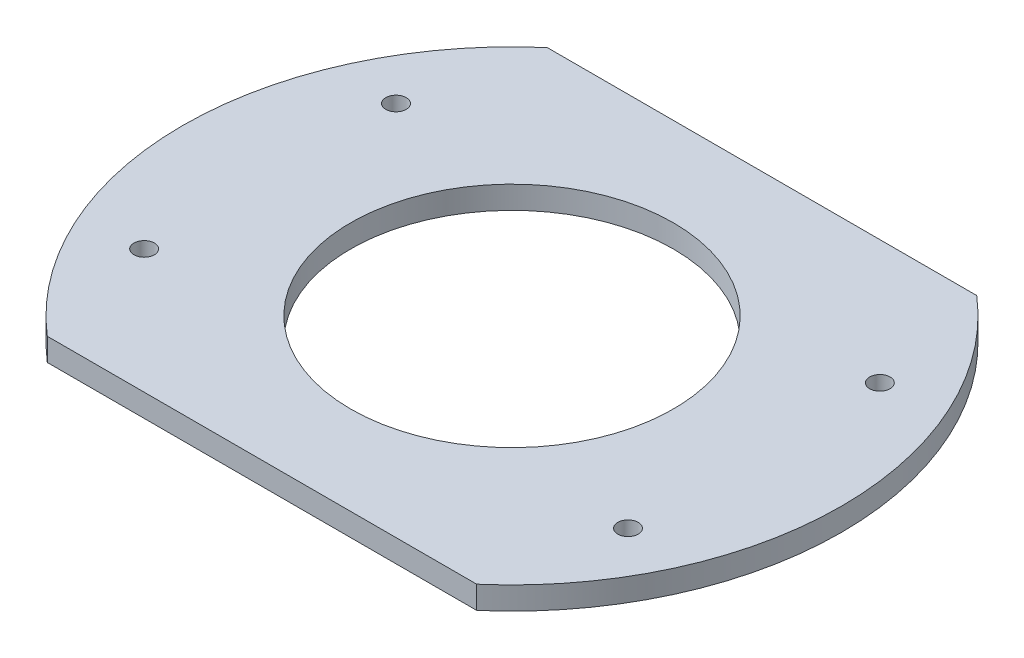
from build123d import *

# Parameters (mm, degrees)
SKETCH_1_R      = 35.5
SKETCH_1_R_2    = 2.25
EXTRUDE_1_DEPTH = 5


with BuildPart() as part:
    # Эскиз1 → Бобышка-Вытянуть1 (new body)
    with BuildSketch(Plane(origin=(0, 0, 0), x_dir=(1, 0, 0), z_dir=(0, 1, 0))):
        with BuildLine():
            Line((-47.236109069, -55), (47.236109069, -55))
            ThreePointArc((47.236109069, -55), (72.5, 0), (47.236109069, 55))
            Line((47.236109069, 55), (-47.236109069, 55))
            ThreePointArc((-47.236109069, 55), (-72.5, 0), (-47.236109069, -55))
        make_face()
        Circle(SKETCH_1_R, mode=Mode.SUBTRACT)
        with Locations((53.220649991, 27.704916794)):
            Circle(SKETCH_1_R_2, mode=Mode.SUBTRACT)
        with Locations((53.220649991, -27.704916794)):
            Circle(SKETCH_1_R_2, mode=Mode.SUBTRACT)
        with Locations((-53.220649991, -27.704916794)):
            Circle(SKETCH_1_R_2, mode=Mode.SUBTRACT)
        with Locations((-53.220649991, 27.704916794)):
            Circle(SKETCH_1_R_2, mode=Mode.SUBTRACT)
    extrude(amount=EXTRUDE_1_DEPTH)


solid = part.part
